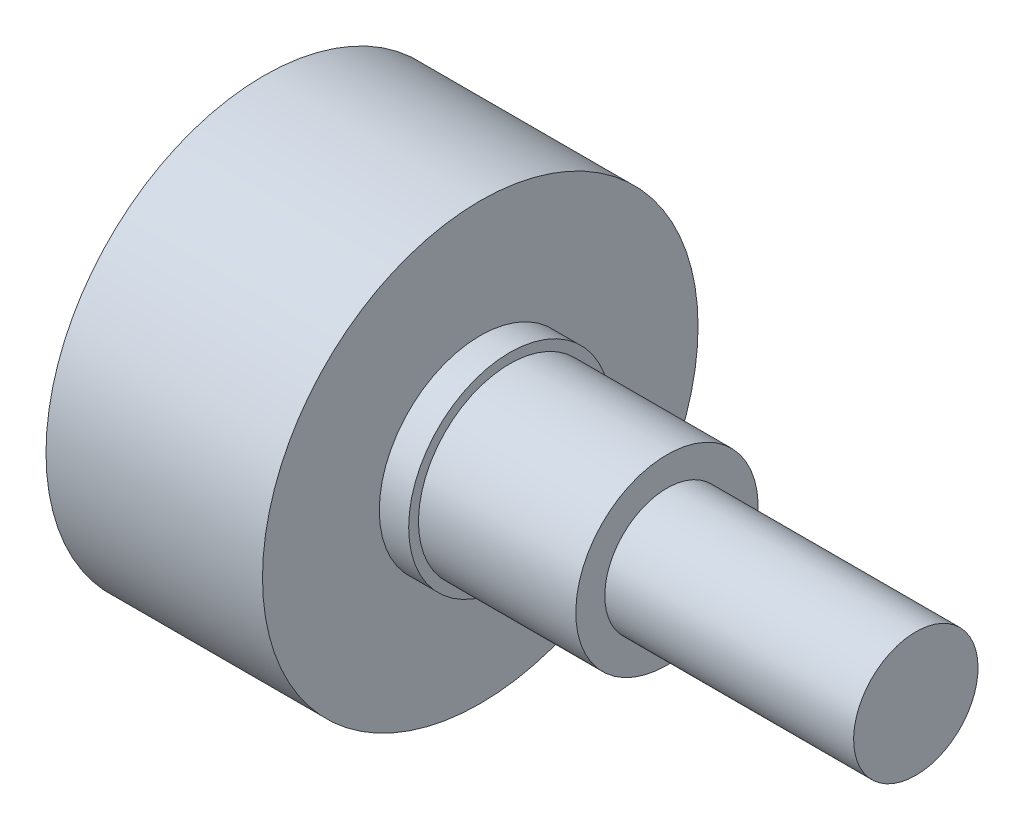
from build123d import *

# Parameters (mm, degrees)
SKETCH2_R           = 1
BOSS_EXTRUDE1_DEPTH = 2.49


with BuildPart() as part:
    # Sketch1 → Revolve1 (revolve)
    with BuildSketch(Plane.XY):
        Polygon((-16.64, 0), (16.64, 0), (16.64, 3.175), (3.94, 3.175), (3.94, 4.655), (-4.09, 4.655), (-4.09, 5.155), (-5.59, 5.155), (-5.59, 11.115), (-16.64, 11.115), align=None)
    revolve(axis=Axis((-16.64, 0, 0), (1, 0, 0)))

    # Sketch2 → Boss-Extrude1 (add)
    with BuildSketch(Plane.ZY.offset(16.64)):
        with Locations((-3.905, 3.908529135)):
            Circle(SKETCH2_R)
        with Locations((3.905, 3.908529135)):
            Circle(SKETCH2_R)
        with Locations((0, -5.525)):
            Circle(SKETCH2_R)
    extrude(amount=BOSS_EXTRUDE1_DEPTH)


solid = part.part
